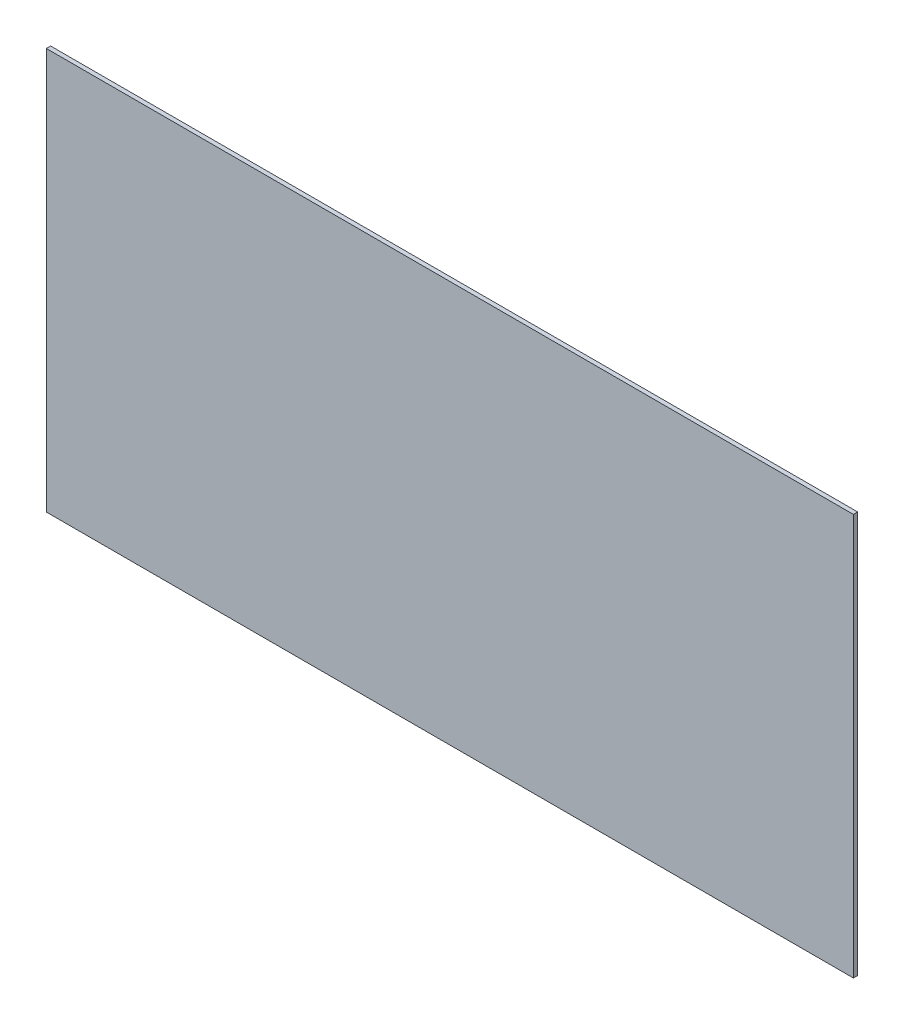
from build123d import *

# Parameters (mm, degrees)
ESQUISSE1_W        = 300
ESQUISSE1_H        = 149.25
BOSS_EXTRU_1_DEPTH = 1.5875


with BuildPart() as part:
    # Esquisse1 → Boss.-Extru.1 (new body)
    with BuildSketch(Plane.XY):
        with Locations((17.590145924, 1.681690141)):
            Rectangle(ESQUISSE1_W, ESQUISSE1_H)
    extrude(amount=BOSS_EXTRU_1_DEPTH)


solid = part.part
